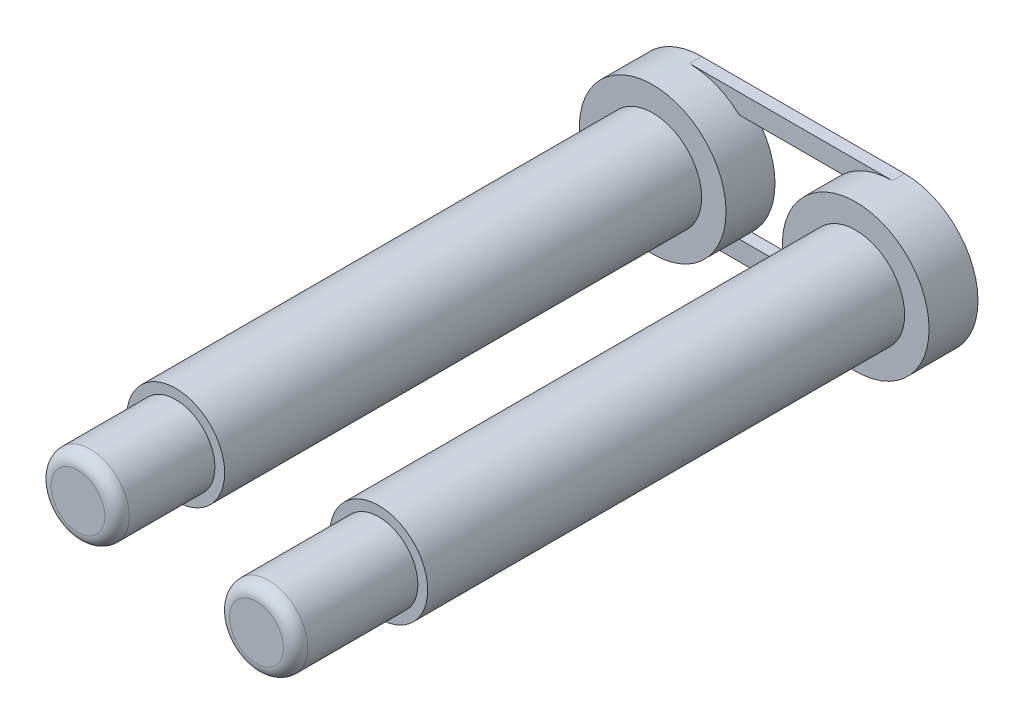
from build123d import *

# Parameters (mm, degrees)
SKETCH_2_R        = 2
SKETCH_2_R_2      = 1.6
EXTRUDE_3_DEPTH   = 21.5
EXTRUDE_3_2_DEPTH = 21.5
SKETCH_2_8_R      = 1.6
EXTRUDE_4_DEPTH   = 26.5
SKETCH_2_9_R      = 3
SKETCH_2_9_R_2    = 2
EXTRUDE_5_DEPTH   = 2
EXTRUDE_7_DEPTH   = 0.5
FILLET_1_R        = 0.5
SKETCH_2_12_R     = 1.6
EXTRUDE_8_DEPTH   = 25.5
FILLET_3_R        = 0.5


with BuildPart() as part:
    # 草图2 → 凸台-拉伸3 (new body)
    with BuildSketch(Plane.XY):
        with Locations((23.5, 37.3)):
            Circle(SKETCH_2_R)
        with Locations((23.5, 37.3)):
            Circle(SKETCH_2_R_2, mode=Mode.SUBTRACT)
    extrude(amount=EXTRUDE_3_DEPTH)

    # 草图2<8> → 凸台-拉伸4 (add)
    with BuildSketch(Plane.XY):
        with Locations((23.5, 37.3)):
            Circle(SKETCH_2_8_R)
    extrude(amount=EXTRUDE_4_DEPTH)

    # 草图2<9> → 凸台-拉伸5 (add)
    # profile 1 of 2: a face of its own
    with BuildSketch(Plane.XY):
        with Locations((15.2, 37.3)):
            Circle(SKETCH_2_9_R)
        with Locations((15.2, 37.3)):
            Circle(SKETCH_2_9_R_2, mode=Mode.SUBTRACT)
    # profile 2 of 2: a face of its own
    with BuildSketch(Plane.XY):
        with Locations((23.5, 37.3)):
            Circle(SKETCH_2_9_R)
        with Locations((23.5, 37.3)):
            Circle(SKETCH_2_9_R_2, mode=Mode.SUBTRACT)
    extrude(amount=EXTRUDE_5_DEPTH)


with BuildPart() as body_2:
    # 草图2 → Extrude 3 2 (new body)
    with BuildSketch(Plane.XY):
        with Locations((15.2, 37.3)):
            Circle(SKETCH_2_R)
        with Locations((15.2, 37.3)):
            Circle(SKETCH_2_R_2, mode=Mode.SUBTRACT)
    extrude(amount=EXTRUDE_3_2_DEPTH)


with BuildPart() as extrude_5_piece_1:
    # of the separate pieces the step leaves, piece 1, a body of its own (extrude_5_pieces)
    add(part.part.solids().sort_by_distance((25.5, 37.3, 2))[0])

    # 草图2<11> → 凸台-拉伸7 (add)
    with BuildSketch(Plane.XY):
        with BuildLine():
            ThreePointArc((17.239607805, 35.1), (16.295445115, 34.507151991), (15.2, 34.3))
            Line((15.2, 34.3), (23.5, 34.3))
            ThreePointArc((23.5, 34.3), (22.404554885, 34.507151991), (21.460392195, 35.1))
            Line((21.460392195, 35.1), (17.239607805, 35.1))
        make_face()
        with BuildLine():
            Line((23.5, 40.3), (15.2, 40.3))
            ThreePointArc((15.2, 40.3), (16.295445115, 40.092848009), (17.239607805, 39.5))
            Line((17.239607805, 39.5), (21.460392195, 39.5))
            ThreePointArc((21.460392195, 39.5), (22.404554885, 40.092848009), (23.5, 40.3))
        make_face()
    extrude(amount=EXTRUDE_7_DEPTH)

    # 圆角1
    fillet_1_edges = [extrude_5_piece_1.edges().sort_by_distance(p)[0] for p in [
        (21.9, 37.3, 26.5),
    ]]
    fillet(fillet_1_edges, radius=FILLET_1_R)



with BuildPart() as extrude_5_piece_2:
    # of the separate pieces the step leaves, piece 2, a body of its own (extrude_5_pieces)
    add(part.part.solids().sort_by_distance((18.2, 37.3, 0))[0])


with BuildPart() as extrude_5_piece_1_1:
    add(extrude_5_piece_1.part)

    add(extrude_5_piece_2.part)  # 凸台-拉伸8 merges 凸台-拉伸5 piece 2

    add(body_2.part)  # 凸台-拉伸8 merges body 2
    # 草图2<12> → 凸台-拉伸8 (add)
    with BuildSketch(Plane.XY):
        with Locations((15.2, 37.3)):
            Circle(SKETCH_2_12_R)
    extrude(amount=EXTRUDE_8_DEPTH)

    # 圆角3
    fillet_3_edges = [extrude_5_piece_1_1.edges().sort_by_distance(p)[0] for p in [
        (13.6, 37.3, 25.5),
    ]]
    fillet(fillet_3_edges, radius=FILLET_3_R)


solid = extrude_5_piece_1_1.part
